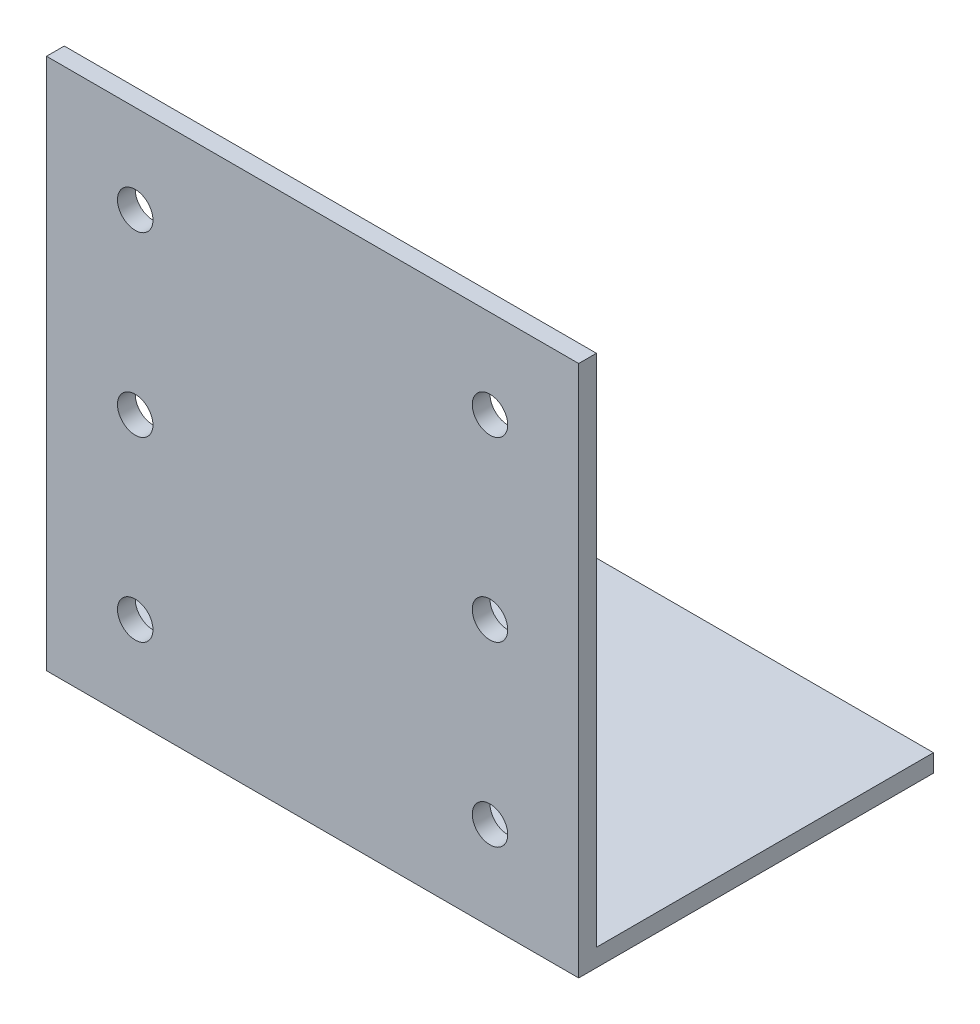
from build123d import *

# Parameters (mm, degrees)
EXTRUDE_1_DEPTH     = 60
SKETCH_2_R          = 2
CUT_EXTRUDE_1_DEPTH = 41


with BuildPart() as part:
    # Эскиз1 → Вытянуть-Тонкостенный1 (new body)
    with BuildSketch(Plane(origin=(0, 0, 0), x_dir=(0, 0, -1), z_dir=(1, 0, 0))):
        Polygon((40, 0), (0, 0), (0, 60), (2, 60), (2, 2), (40, 2), align=None)
    extrude(amount=EXTRUDE_1_DEPTH)

    # Эскиз2 → Вырез-Вытянуть1 (cut, through all)
    with BuildSketch(Plane.XY):
        with Locations((10, 50)):
            Circle(SKETCH_2_R)
        with Locations((50, 50)):
            Circle(SKETCH_2_R)
        with Locations((50, 30)):
            Circle(SKETCH_2_R)
        with Locations((50, 10)):
            Circle(SKETCH_2_R)
        with Locations((10, 30)):
            Circle(SKETCH_2_R)
        with Locations((10, 10)):
            Circle(SKETCH_2_R)
    extrude(amount=-CUT_EXTRUDE_1_DEPTH, mode=Mode.SUBTRACT)


solid = part.part
